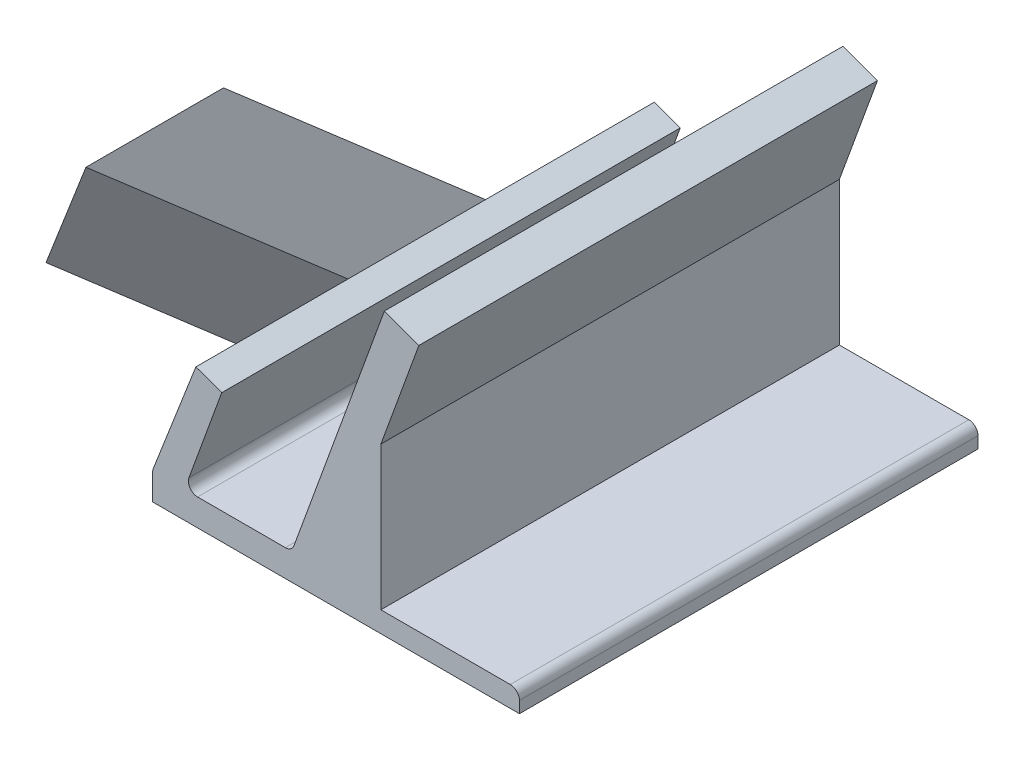
from build123d import *

# Parameters (mm, degrees)
SALIENTE_EXTRUIR1_DEPTH = 50
CROQUIS3_W              = 15
CROQUIS3_H              = 12


with BuildPart() as part:
    # Croquis1 → Saliente-Extruir1 (new body)
    with BuildSketch(Plane.XY):
        with BuildLine():
            Line((-84.492533904, -6.921751872), (-44.492533904, -6.921751872))
            Line((-44.492533904, -6.921751872), (-44.492533904, -5.660932217))
            ThreePointArc((-44.492533904, -5.660932217), (-44.785427123, -4.953825435), (-45.492533904, -4.660932217))
            Line((-45.492533904, -4.660932217), (-59.602097354, -4.660932217))
            Line((-59.602097354, -4.660932217), (-59.602097354, 10.986403293))
            Line((-59.602097354, 10.986403293), (-55.79772825, 21.438821499))
            Line((-55.79772825, 21.438821499), (-55.455708107, 22.37851412))
            Line((-55.455708107, 22.37851412), (-59.21447859, 23.746594693))
            Line((-59.21447859, 23.746594693), (-59.556498733, 22.806902073))
            Line((-59.556498733, 22.806902073), (-69.073702494, -3.341400356))
            ThreePointArc((-69.073702494, -3.341400356), (-69.439818678, -3.818532257), (-70.013395115, -3.999380213))
            Line((-70.013395115, -3.999380213), (-79.590995067, -3.999380213))
            ThreePointArc((-79.590995067, -3.999380213), (-80.410147111, -3.572956649), (-80.530687688, -2.657360069))
            Line((-80.530687688, -2.657360069), (-77.297371662, 6.226102703))
            Line((-77.297371662, 6.226102703), (-76.955351518, 7.165795324))
            Line((-76.955351518, 7.165795324), (-79.774429381, 8.191855754))
            Line((-79.774429381, 8.191855754), (-80.129339821, 7.280632657))
            Line((-80.129339821, 7.280632657), (-84.424349875, -3.746691195))
            ThreePointArc((-84.424349875, -3.746691195), (-84.475340083, -3.924982082), (-84.492533904, -4.109622312))
            Line((-84.492533904, -4.109622312), (-84.492533904, -6.921751872))
        make_face()
    extrude(amount=SALIENTE_EXTRUIR1_DEPTH)

    # Barrer9: sweep along a path in Croquis7
    with BuildLine(Plane(origin=(-43.940534578, 17.114309903, -27.225418163), x_dir=(0.465907986, -0.181465559, -0.866025404), z_dir=(0.806976303, -0.314307567, 0.5))) as barrer9_path:
        Line((-60.30471847, -28.214335671), (-86.285480583, -13.214335671))
    # Croquis3 → Barrer9 (sweep)
    with BuildSketch(Plane(origin=(-72.036984482, 28.057539326, 0), x_dir=(0, 0, 1), z_dir=(-0.931815971, 0.362931117, 0))):
        with Locations((25, -28.214335671)):
            Rectangle(CROQUIS3_W, CROQUIS3_H)
    sweep(path=barrer9_path.line)


solid = part.part
